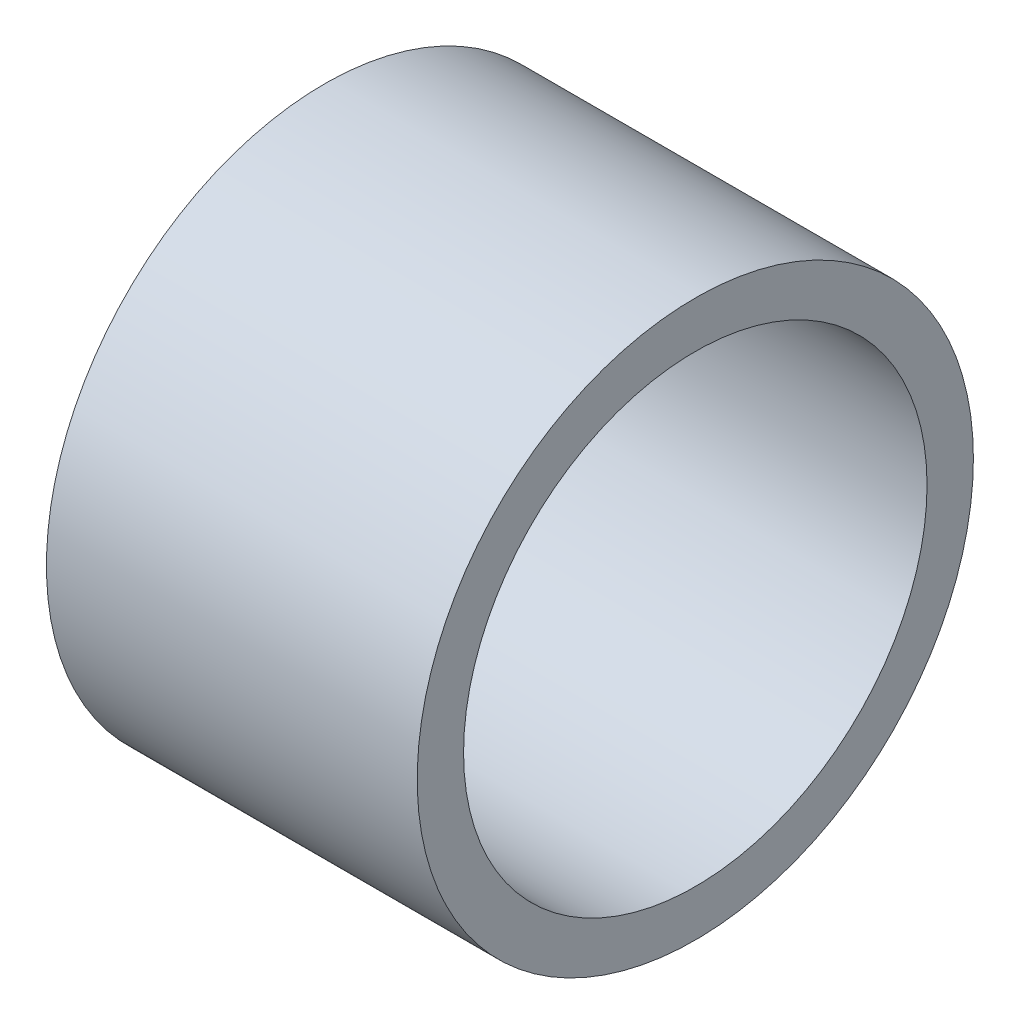
from build123d import *

# Parameters (mm, degrees)
SKETCH_4_R          = 30
EXTRUDE_2_DEPTH     = 20
SKETCH_5_R          = 25
CUT_EXTRUDE_2_DEPTH = 41


with BuildPart() as part:
    # Эскиз4 → Бобышка-Вытянуть2 (new body, symmetric)
    with BuildSketch(Plane(origin=(0, 0, 0), x_dir=(0, 0, -1), z_dir=(1, 0, 0))):
        Circle(SKETCH_4_R)
    extrude(amount=EXTRUDE_2_DEPTH, both=True)

    # Эскиз5 → Вырез-Вытянуть2 (cut, through all)
    with BuildSketch(Plane(origin=(20, 0, 0), x_dir=(0, 0, -1), z_dir=(1, 0, 0))):
        Circle(SKETCH_5_R)
    extrude(amount=-CUT_EXTRUDE_2_DEPTH, mode=Mode.SUBTRACT)


solid = part.part
